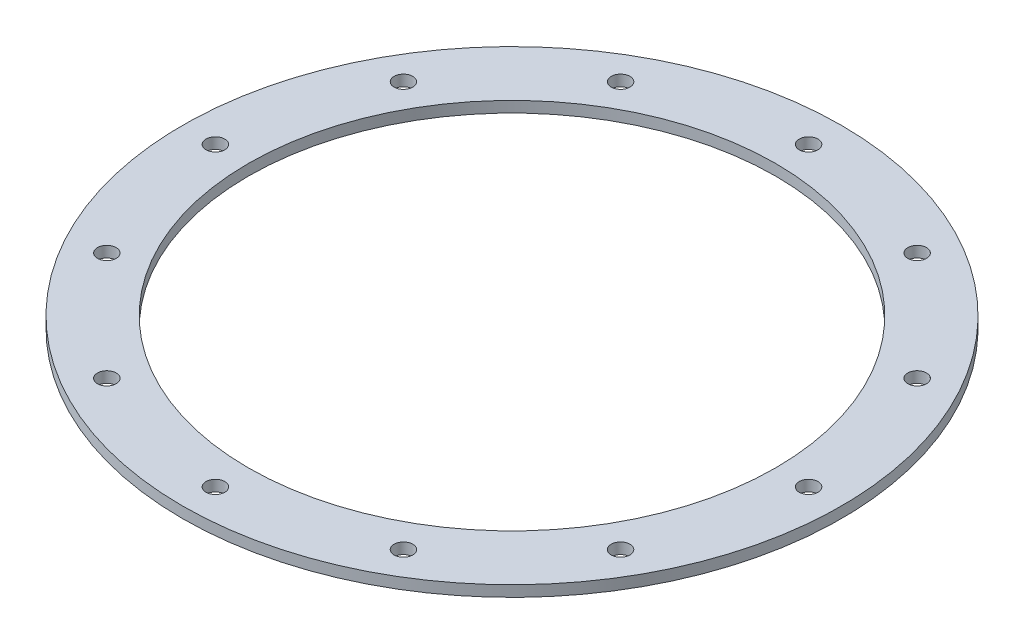
from build123d import *

# Parameters (mm, degrees)
SKETCH1_W                    = 9.525
SKETCH1_H                    = 1.5875
F_36_0_1065_DIAMETER_HOLE1_D = 2.7051
SCREW_PASSTHROUGHS_COUNT     = 12


with BuildPart() as part:
    # Sketch1 → Main (revolve)
    with BuildSketch(Plane.XY):
        with Locations((-42.8625, 0.79375)):
            Rectangle(SKETCH1_W, SKETCH1_H)
    revolve(axis=Axis((0, 55, 0), (0, -1, 0)))

    # #36 (0.1065) Diameter Hole1 (through all)
    with Locations(Plane(origin=(0, 0, 0), x_dir=(-1, 0, 0), z_dir=(0, -1, 0))):
        with Locations((42.8625, 0)):
            f_36_0_1065_diameter_hole1 = Hole(F_36_0_1065_DIAMETER_HOLE1_D / 2)

    # Screw Passthroughs: #36 (0.1065) Diameter Hole1 ×12 about axis
    screw_passthroughs_axis = Axis((0, 0, 0), (0, 1, 0))
    for i in range(1, SCREW_PASSTHROUGHS_COUNT):
        add(f_36_0_1065_diameter_hole1.rotate(screw_passthroughs_axis, i * 360 / SCREW_PASSTHROUGHS_COUNT), mode=Mode.SUBTRACT)


solid = part.part
